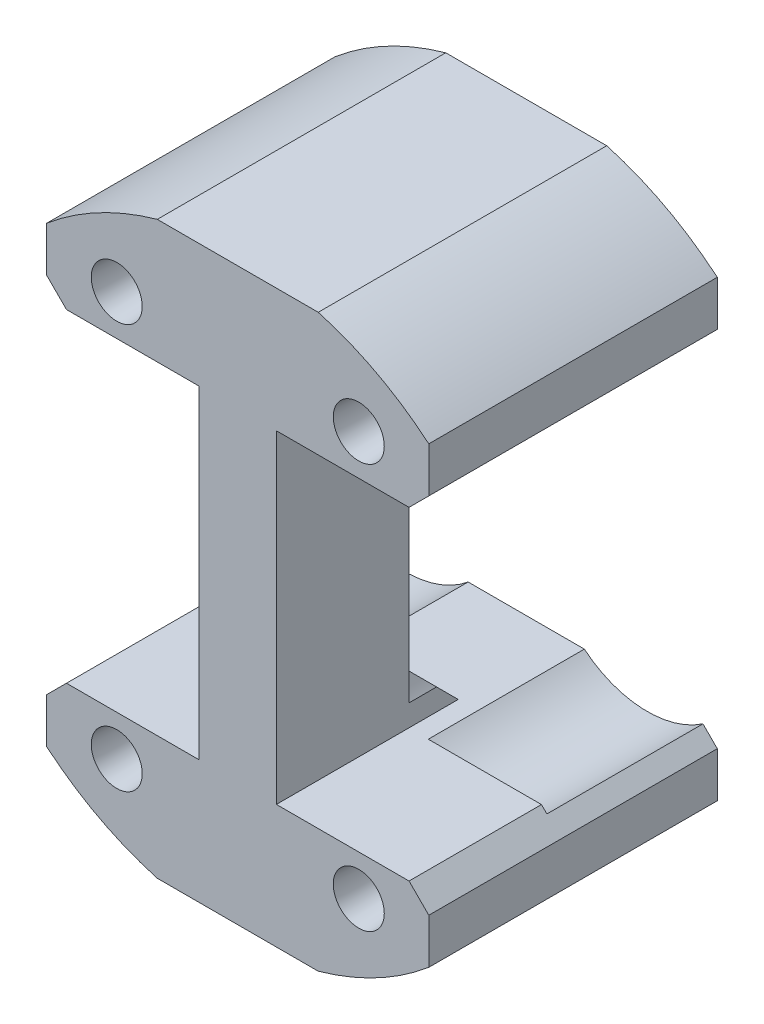
from build123d import *

# Parameters (mm, degrees)
SKETCH1_W                 = 24.553215102
SKETCH1_H                 = 7.9375
BOSS_EXTRUDE1_DEPTH       = 18.5375
CUT_EXTRUDE2_DEPTH        = 19.5375
SKETCH3_W                 = 4.965715102
SKETCH3_H                 = 20.79375
BOSS_EXTRUDE2_DEPTH       = 8.509
CHAMFER2_SIZE             = 3.175
CHAMFER4_SIZE             = 1.27
CUT_EXTRUDE1_DEPTH        = 10.0285
HOLE1_AT_2_COUNT          = 2
HOLE1_AT_2_PITCH          = 15.553215102
HOLE1_AT_3_COUNT          = 2
HOLE1_AT_3_PITCH          = 30.296905783
HOLE1_AT_4_COUNT          = 2
HOLE1_AT_4_PITCH          = 26
F_0_CLEARANCE_HOLE1_D     = 1.8542
F_0_CLEARANCE_HOLE1_DEPTH = 6.35
F_0_CLEARANCE_HOLE1_TIP   = 0.55705788
HOLE2_AT_2_COUNT          = 2
HOLE2_AT_2_PITCH          = 15.182467652
HOLE2_AT_3_COUNT          = 2
HOLE2_AT_3_PITCH          = 29.379980379
HOLE2_AT_4_COUNT          = 2
HOLE2_AT_4_PITCH          = 33.075076063
F_0_CLEARANCE_HOLE2_D     = 1.8542
F_0_CLEARANCE_HOLE2_DEPTH = 6.35
F_0_CLEARANCE_HOLE2_TIP   = 0.55705788


with BuildPart() as part:
    # Sketch1 → Boss-Extrude1 (new body)
    with BuildSketch(Plane.XY):
        with Locations((0, -14.365625)):
            Rectangle(SKETCH1_W, SKETCH1_H)
    extrude(amount=BOSS_EXTRUDE1_DEPTH)

    # Sketch8 → Cut-Extrude2 (cut, through all)
    with BuildSketch(Plane(origin=(0, 0, 0), x_dir=(-1, 0, 0), z_dir=(0, 0, -1))):
        with BuildLine():
            Line((5.172348921, -18.334375), (12.276607551, -18.334375))
            Line((12.276607551, -18.334375), (12.276607551, -14.566653941))
            ThreePointArc((12.276607551, -14.566653941), (8.925550458, -16.829647917), (5.172348921, -18.334375))
        make_face()
        with BuildLine():
            Line((-12.276607551, -14.566653941), (-12.276607551, -18.334375))
            Line((-12.276607551, -18.334375), (-5.172348921, -18.334375))
            ThreePointArc((-5.172348921, -18.334375), (-8.925550458, -16.829647917), (-12.276607551, -14.566653941))
        make_face()
    extrude(amount=-CUT_EXTRUDE2_DEPTH, mode=Mode.SUBTRACT)


with BuildPart() as body_2:
    # Mirror2: mirrored copy
    add(part.part.mirror(Plane(origin=(0, 0, 0), x_dir=(0, 0, 1), z_dir=(0, -1, 0))))


with BuildPart() as part_1:
    add(part.part)

    add(body_2.part)  # Boss-Extrude2 merges body 2
    # Sketch3 → Boss-Extrude2 (add)
    with BuildSketch(Plane.XY.offset(18.5375)):
        Rectangle(SKETCH3_W, SKETCH3_H)
    extrude(amount=-BOSS_EXTRUDE2_DEPTH)

    # Chamfer2
    chamfer2_edges = [part_1.edges().sort_by_distance(p)[0] for p in [
        (0, 10.396875, 10.0285),
        (0, -10.396875, 10.0285),
    ]]
    chamfer(chamfer2_edges, length=CHAMFER2_SIZE)

    # Chamfer4
    chamfer4_edges = [part_1.edges().sort_by_distance(p)[0] for p in [
        (-12.276607551, -10.396875, 9.26875),
        (12.276607551, -10.396875, 9.26875),
        (-12.276607551, 10.396875, 9.26875),
        (12.276607551, 10.396875, 9.26875),
    ]]
    chamfer(chamfer4_edges, length=CHAMFER4_SIZE)

    # Sketch2 → Cut-Extrude1 (cut)
    with BuildSketch(Plane(origin=(0, 0, 0), x_dir=(-1, 0, 0), z_dir=(0, 0, -1))):
        with BuildLine():
            ThreePointArc((4.602887336, 0), (7.776607551, -11.85), (10.950327765, 0))
            ThreePointArc((10.950327765, 0), (7.776607551, 11.85), (4.602887336, 0))
        make_face()
        with BuildLine():
            ThreePointArc((-10.950327765, 0), (-7.776607551, -11.85), (-4.602887336, 0))
            ThreePointArc((-4.602887336, 0), (-7.776607551, 11.85), (-10.950327765, 0))
        make_face()
    extrude(amount=-CUT_EXTRUDE1_DEPTH, mode=Mode.SUBTRACT)

    # Sketch5 → Hole1 (revolve, cut)
    with BuildSketch(Plane(origin=(-7.776607551, 13, 18.5375), x_dir=(0, -1, 0), z_dir=(1, 0, 0))):
        Polygon((0, 0), (0, 2.921), (1.4986, 2.921), (1.6383, 0), align=None)
    hole1 = revolve(axis=Axis((-7.776607551, 13, -91.4625), (0, 0, 1)), mode=Mode.SUBTRACT)

    # Hole1 at 2: Hole1 ×2
    with Locations(*[(i * HOLE1_AT_2_PITCH, 0, 0) for i in range(1, HOLE1_AT_2_COUNT)]):
        add(hole1, mode=Mode.SUBTRACT)

    # Hole1 at 3: Hole1 ×2
    with Locations(*[Vector(0.513359853, -0.858173445, 0) * (i * HOLE1_AT_3_PITCH) for i in range(1, HOLE1_AT_3_COUNT)]):
        add(hole1, mode=Mode.SUBTRACT)

    # Hole1 at 4: Hole1 ×2
    with Locations(*[(0, -i * HOLE1_AT_4_PITCH, 0) for i in range(1, HOLE1_AT_4_COUNT)]):
        add(hole1, mode=Mode.SUBTRACT)

    # #0 Clearance Hole1
    with Locations(Plane.XY.offset(18.5375)):
        with Locations((7.776607551, 13), (7.776607551, -13), (-7.776607551, -13), (-7.776607551, 13)):
            Hole(F_0_CLEARANCE_HOLE1_D / 2, depth=F_0_CLEARANCE_HOLE1_DEPTH)
            with Locations((0, 0, -(F_0_CLEARANCE_HOLE1_DEPTH + F_0_CLEARANCE_HOLE1_TIP / 2))):  # 118° drill point
                Cone(0, F_0_CLEARANCE_HOLE1_D / 2, F_0_CLEARANCE_HOLE1_TIP, mode=Mode.SUBTRACT)

    # Sketch9 → Hole2 (revolve, cut)
    with BuildSketch(Plane(origin=(7.435045578, -14.689990189, 0), x_dir=(0, 1, 0), z_dir=(1, 0, 0))):
        Polygon((0, 0), (0, 2.921), (1.4986, 2.921), (1.6383, 0), align=None)
    hole2 = revolve(axis=Axis((7.435045578, -14.689990189, 110), (0, 0, -1)), mode=Mode.SUBTRACT)

    # Hole2 at 2: Hole2 ×2
    with Locations(*[Vector(-0.999999954, -0.000302745, 0) * (i * HOLE2_AT_2_PITCH) for i in range(1, HOLE2_AT_2_COUNT)]):
        add(hole2, mode=Mode.SUBTRACT)

    # Hole2 at 3: Hole2 ×2
    with Locations(*[(0, i * HOLE2_AT_3_PITCH, 0) for i in range(1, HOLE2_AT_3_COUNT)]):
        add(hole2, mode=Mode.SUBTRACT)

    # Hole2 at 4: Hole2 ×2
    with Locations(*[Vector(-0.459030447, 0.888420536, 0) * (i * HOLE2_AT_4_PITCH) for i in range(1, HOLE2_AT_4_COUNT)]):
        add(hole2, mode=Mode.SUBTRACT)

    # #0 Clearance Hole2
    with Locations(Plane(origin=(0, 0, 0), x_dir=(-1, 0, 0), z_dir=(0, 0, -1))):
        with Locations((-7.435045578, -14.689990189), (-7.435045578, 14.689990189), (7.747421379, 14.69458661), (7.747421379, -14.69458661)):
            Hole(F_0_CLEARANCE_HOLE2_D / 2, depth=F_0_CLEARANCE_HOLE2_DEPTH)
            with Locations((0, 0, -(F_0_CLEARANCE_HOLE2_DEPTH + F_0_CLEARANCE_HOLE2_TIP / 2))):  # 118° drill point
                Cone(0, F_0_CLEARANCE_HOLE2_D / 2, F_0_CLEARANCE_HOLE2_TIP, mode=Mode.SUBTRACT)


solid = part_1.part
